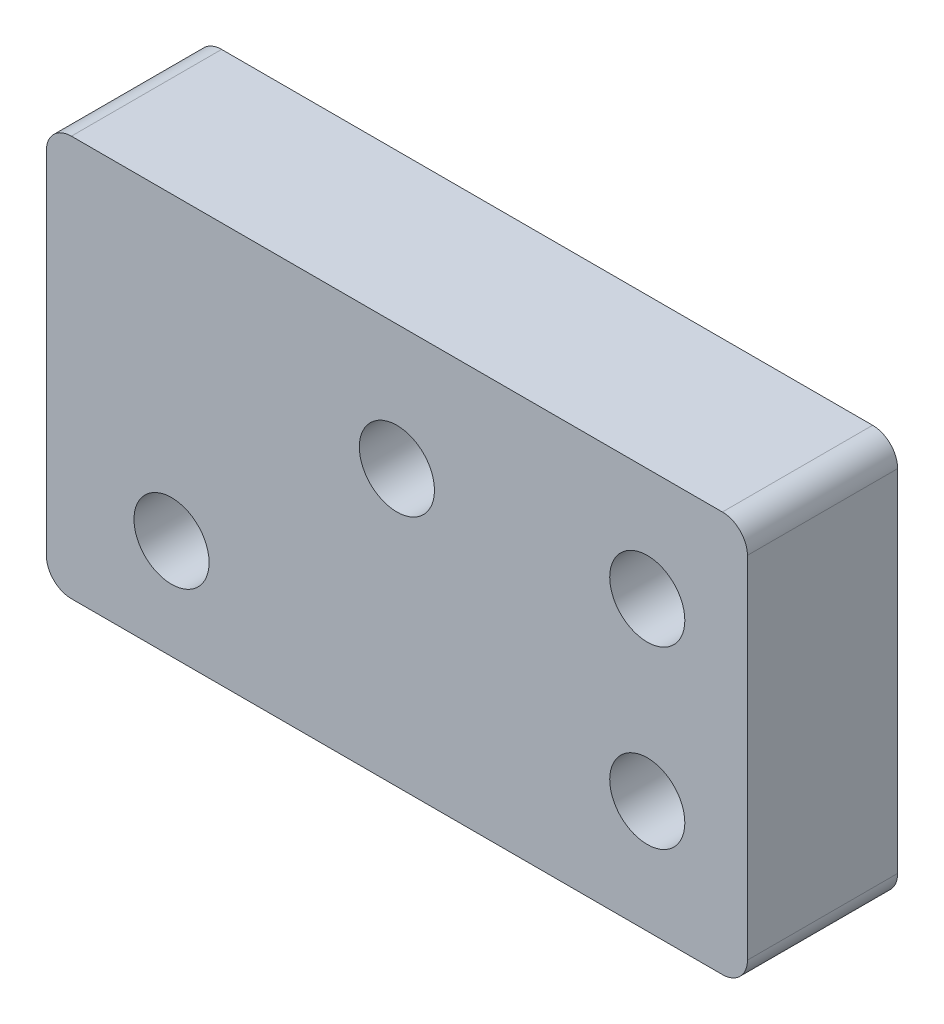
from build123d import *

# Parameters (mm, degrees)
SKETCH_1_W          = 28
SKETCH_1_H          = 16
EXTRUDE_1_DEPTH     = 6
SKETCH_2_R          = 2.85
CUT_EXTRUDE_1_DEPTH = 3.2
SKETCH_3_R          = 1.5
CUT_EXTRUDE_2_DEPTH = 3.2
FILLET_1_R          = 1
SKETCH_4_R          = 1.5
CUT_EXTRUDE_3_DEPTH = 10


with BuildPart() as part:
    # 草图1 → 凸台-拉伸1 (new body)
    with BuildSketch(Plane.XY):
        Rectangle(SKETCH_1_W, SKETCH_1_H)
    extrude(amount=EXTRUDE_1_DEPTH)

    # 草图2 → 切除-拉伸1 (cut)
    with BuildSketch(Plane(origin=(0, 0, 0), x_dir=(-1, 0, 0), z_dir=(0, 0, -1))):
        with Locations((-10, 3.5)):
            Circle(SKETCH_2_R)
        with Locations((-10, -3.5)):
            Circle(SKETCH_2_R)
    extrude(amount=-CUT_EXTRUDE_1_DEPTH, mode=Mode.SUBTRACT)

    # 草图3 → 切除-拉伸2 (cut)
    with BuildSketch(Plane(origin=(0, 0, 3.2), x_dir=(-1, 0, 0), z_dir=(0, 0, -1))):
        with Locations((-10, 3.5)):
            Circle(SKETCH_3_R)
        with Locations((-10, -3.5)):
            Circle(SKETCH_3_R)
    extrude(amount=-CUT_EXTRUDE_2_DEPTH, mode=Mode.SUBTRACT)

    # 圆角1
    fillet_1_edges = [part.edges().sort_by_distance(p)[0] for p in [
        (-14, 8, 3),
        (14, 8, 3),
        (14, -8, 3),
        (-14, -8, 3),
    ]]
    fillet(fillet_1_edges, radius=FILLET_1_R)

    # 草图4 → 切除-拉伸3 (cut)
    with BuildSketch(Plane.XY.offset(6)):
        with Locations((0, 3)):
            Circle(SKETCH_4_R)
        with Locations((-9, -4)):
            Circle(SKETCH_4_R)
    extrude(amount=-CUT_EXTRUDE_3_DEPTH, mode=Mode.SUBTRACT)


solid = part.part
